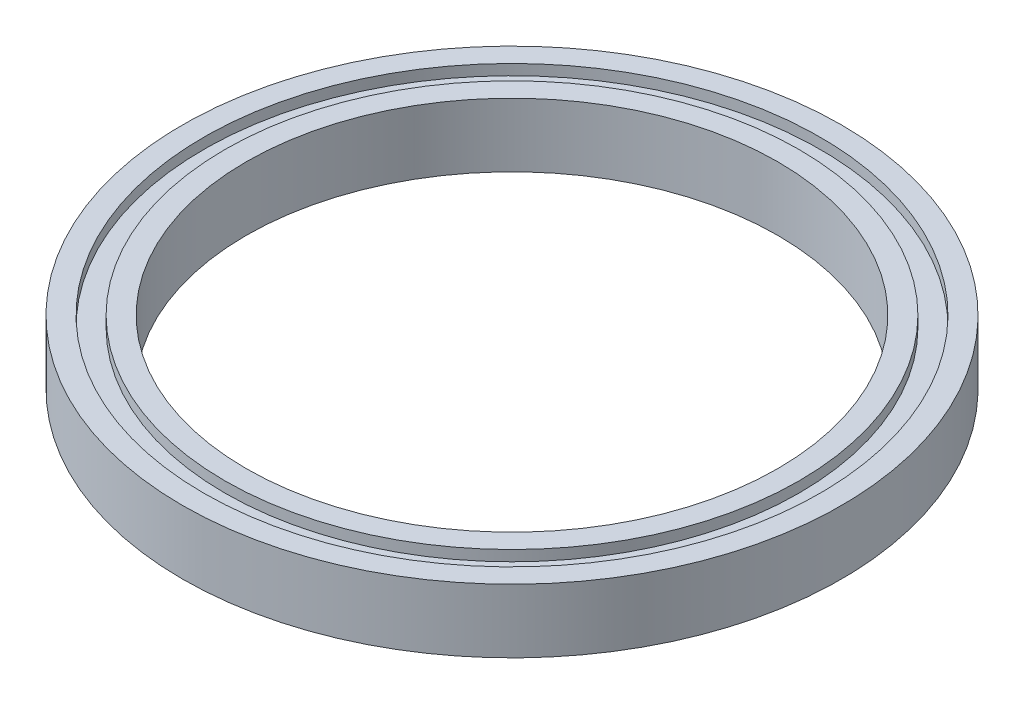
from build123d import *

# Parameters (mm, degrees)
SKETCH1_R           = 31
SKETCH1_R_2         = 25
BOSS_EXTRUDE1_DEPTH = 6
SKETCH2_R           = 29
SKETCH2_R_2         = 27
CUT_EXTRUDE1_DEPTH  = 1
SKETCH3_R           = 29
SKETCH3_R_2         = 27
CUT_EXTRUDE2_DEPTH  = 1


with BuildPart() as part:
    # Sketch1 → Boss-Extrude1 (new body)
    with BuildSketch(Plane(origin=(0, 0, 0), x_dir=(1, 0, 0), z_dir=(0, 1, 0))):
        Circle(SKETCH1_R)
        Circle(SKETCH1_R_2, mode=Mode.SUBTRACT)
    extrude(amount=BOSS_EXTRUDE1_DEPTH)

    # Sketch2 → Cut-Extrude1 (cut)
    with BuildSketch(Plane(origin=(0, 6, 0), x_dir=(1, 0, 0), z_dir=(0, 1, 0))):
        Circle(SKETCH2_R)
        Circle(SKETCH2_R_2, mode=Mode.SUBTRACT)
    extrude(amount=-CUT_EXTRUDE1_DEPTH, mode=Mode.SUBTRACT)

    # Sketch3 → Cut-Extrude2 (cut)
    with BuildSketch(Plane.XZ):
        Circle(SKETCH3_R)
        Circle(SKETCH3_R_2, mode=Mode.SUBTRACT)
    extrude(amount=-CUT_EXTRUDE2_DEPTH, mode=Mode.SUBTRACT)


solid = part.part
